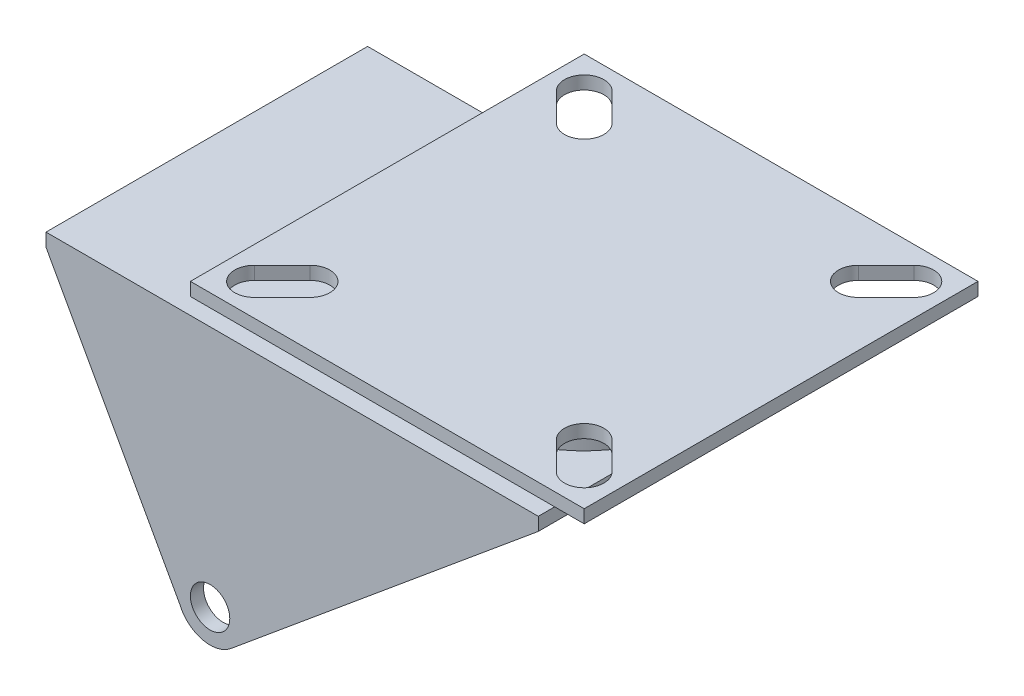
from build123d import *

# Parameters (mm, degrees)
BOSS_EXTRUDE1_START = 2
SKETCH1_R           = 5
SKETCH1_R_2         = 3
BOSS_EXTRUDE1_DEPTH = 2
BOSS_EXTRUDE2_START = 2
SKETCH2_R           = 3
BOSS_EXTRUDE2_DEPTH = 2
SKETCH3_W           = 75
SKETCH3_H           = 49
BOSS_EXTRUDE3_DEPTH = 2
SKETCH4_R           = 17.5
BOSS_EXTRUDE4_DEPTH = 8
SKETCH5_W           = 60
SKETCH5_H           = 60
BOSS_EXTRUDE5_DEPTH = 2


with BuildPart() as part:
    # Sketch1 → Boss-Extrude1 (new body)
    with BuildSketch(Plane.XY.offset(BOSS_EXTRUDE1_START)):
        with BuildLine():
            Line((50, 35), (-25, 35))
            Line((-25, 35), (-4.619219619, -1.91384694))
            ThreePointArc((-4.619219619, -1.91384694), (-0.975679739, 4.903881019), (5, 0))
            ThreePointArc((5, 0), (4.525827035, -2.125297543), (3.193244142, -3.847491631))
            Line((3.193244142, -3.847491631), (50, 35))
        make_face()
        Circle(SKETCH1_R)
        Circle(SKETCH1_R_2, mode=Mode.SUBTRACT)
    extrude(amount=BOSS_EXTRUDE1_DEPTH)



with BuildPart() as body_2:
    # Sketch2 → Boss-Extrude2 (new body)
    with BuildSketch(Plane(origin=(0, 0, -41), x_dir=(-1, 0, 0), z_dir=(0, 0, -1)).offset(BOSS_EXTRUDE2_START)):
        with BuildLine():
            ThreePointArc((-19.679195809, 9.835103065), (-4.101319052, 21.614328165), (14.708637674, 16.360194919))
            Line((14.708637674, 16.360194919), (25, 35))
            Line((25, 35), (-50, 35))
            Line((-50, 35), (-19.679195809, 9.835103065))
        make_face()
        with BuildLine():
            ThreePointArc((-3.193244142, -3.847491631), (1.201289708, -4.853545409), (4.619219619, -1.91384694))
            Line((4.619219619, -1.91384694), (14.708637674, 16.360194919))
            ThreePointArc((14.708637674, 16.360194919), (-4.101319052, 21.614328165), (-19.679195809, 9.835103065))
            Line((-19.679195809, 9.835103065), (-3.193244142, -3.847491631))
        make_face()
        Circle(SKETCH2_R, mode=Mode.SUBTRACT)
    extrude(amount=BOSS_EXTRUDE2_DEPTH)


with BuildPart() as part_1:
    add(part.part)

    add(body_2.part)  # Boss-Extrude3 merges body 2
    # Sketch3 → Boss-Extrude3 (add)
    with BuildSketch(Plane(origin=(0, 35, 0), x_dir=(1, 0, 0), z_dir=(0, 1, 0))):
        with Locations((12.5, 20.5)):
            Rectangle(SKETCH3_W, SKETCH3_H)
    extrude(amount=BOSS_EXTRUDE3_DEPTH)

    # Sketch4 → Boss-Extrude4 (add)
    with BuildSketch(Plane(origin=(0, 37, 0), x_dir=(1, 0, 0), z_dir=(0, 1, 0))):
        with Locations((32.5, 20.5)):
            Circle(SKETCH4_R)
    extrude(amount=BOSS_EXTRUDE4_DEPTH)

    # Sketch5 → Boss-Extrude5 (add)
    with BuildSketch(Plane(origin=(0, 45, 0), x_dir=(1, 0, 0), z_dir=(0, 1, 0))):
        with Locations((32.5, 20.5)):
            Rectangle(SKETCH5_W, SKETCH5_H)
        with BuildLine():
            Line((9.5, 47.742640687), (13.742640687, 43.5))
            ThreePointArc((13.742640687, 43.5), (13.742640687, 39.257359313), (9.5, 39.257359313))
            Line((9.5, 39.257359313), (5.257359313, 43.5))
            ThreePointArc((5.257359313, 43.5), (5.257359313, 47.742640687), (9.5, 47.742640687))
        make_face(mode=Mode.SUBTRACT)
        with BuildLine():
            Line((59.742640687, 43.5), (55.5, 39.257359313))
            ThreePointArc((55.5, 39.257359313), (51.257359313, 39.257359313), (51.257359313, 43.5))
            Line((51.257359313, 43.5), (55.5, 47.742640687))
            ThreePointArc((55.5, 47.742640687), (59.742640687, 47.742640687), (59.742640687, 43.5))
        make_face(mode=Mode.SUBTRACT)
        with BuildLine():
            Line((55.5, -6.742640687), (51.257359313, -2.5))
            ThreePointArc((51.257359313, -2.5), (51.257359313, 1.742640687), (55.5, 1.742640687))
            Line((55.5, 1.742640687), (59.742640687, -2.5))
            ThreePointArc((59.742640687, -2.5), (59.742640687, -6.742640687), (55.5, -6.742640687))
        make_face(mode=Mode.SUBTRACT)
        with BuildLine():
            Line((5.257359313, -2.5), (9.5, 1.742640687))
            ThreePointArc((9.5, 1.742640687), (13.742640687, 1.742640687), (13.742640687, -2.5))
            Line((13.742640687, -2.5), (9.5, -6.742640687))
            ThreePointArc((9.5, -6.742640687), (5.257359313, -6.742640687), (5.257359313, -2.5))
        make_face(mode=Mode.SUBTRACT)
    extrude(amount=BOSS_EXTRUDE5_DEPTH)


solid = part_1.part
